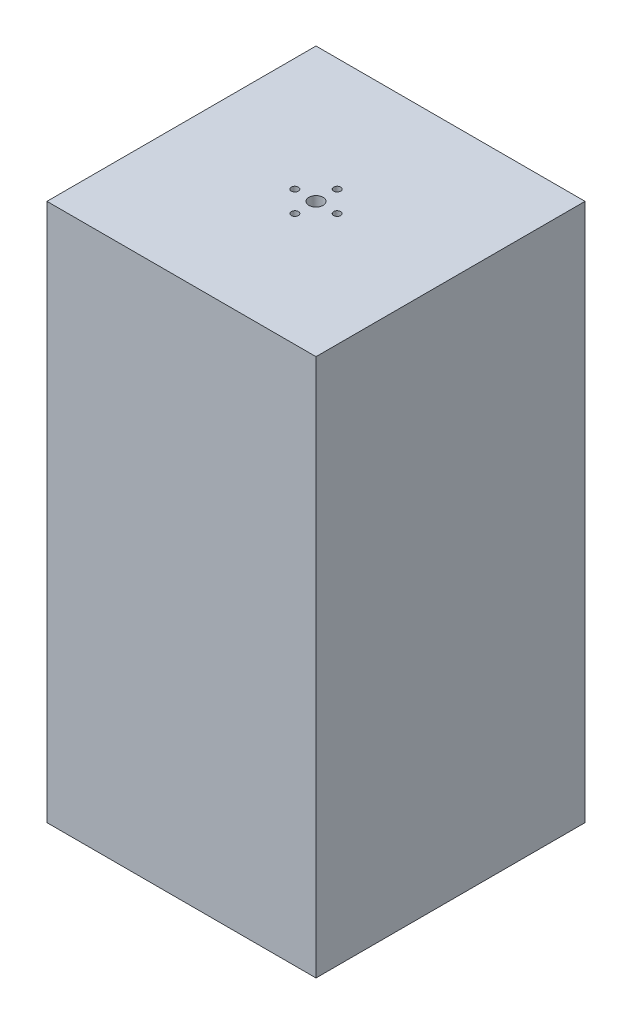
from build123d import *

# Parameters (mm, degrees)
SKETCH1_W           = 76.2
SKETCH1_H           = 152.4
BOSS_EXTRUDE1_DEPTH = 76.2
SKETCH2_W           = 68.58
SKETCH2_H           = 68.58
CUT_EXTRUDE1_DEPTH  = 148.59
SKETCH3_R           = 2
SKETCH3_R_2         = 1
CUT_EXTRUDE2_DEPTH  = 153.4


with BuildPart() as part:
    # Sketch1 → Boss-Extrude1 (new body)
    with BuildSketch(Plane.XY):
        with Locations((38.1, 76.2)):
            Rectangle(SKETCH1_W, SKETCH1_H)
    extrude(amount=-BOSS_EXTRUDE1_DEPTH)

    # Sketch2 → Cut-Extrude1 (cut)
    with BuildSketch(Plane.XZ):
        with Locations((38.1, -38.1)):
            Rectangle(SKETCH2_W, SKETCH2_H)
    extrude(amount=-CUT_EXTRUDE1_DEPTH, mode=Mode.SUBTRACT)

    # Sketch3 → Cut-Extrude2 (cut, through all)
    with BuildSketch(Plane(origin=(0, 152.4, 0), x_dir=(1, 0, 0), z_dir=(0, 1, 0))):
        with Locations((38.1, 38.1)):
            Circle(SKETCH3_R)
        with Locations((38.1, 44.1)):
            Circle(SKETCH3_R_2)
        with Locations((38.1, 32.1)):
            Circle(SKETCH3_R_2)
        with Locations((44.1, 38.1)):
            Circle(SKETCH3_R_2)
        with Locations((32.1, 38.1)):
            Circle(SKETCH3_R_2)
    extrude(amount=-CUT_EXTRUDE2_DEPTH, mode=Mode.SUBTRACT)


solid = part.part
